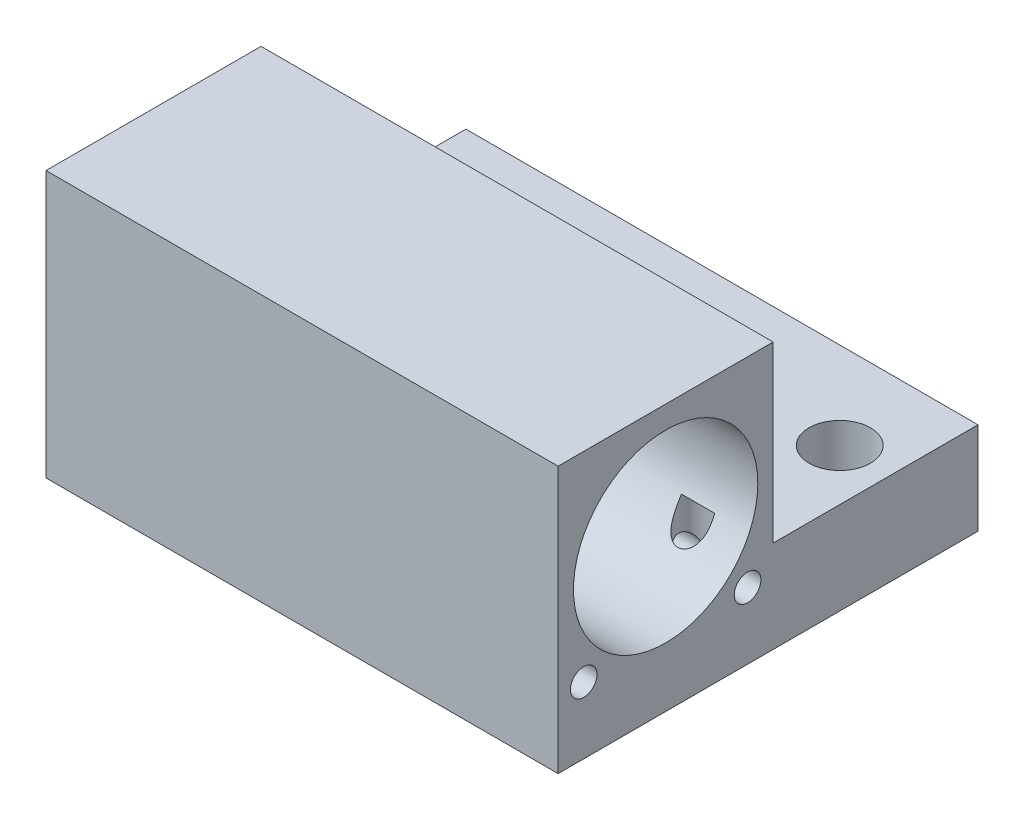
from build123d import *

# Parameters (mm, degrees)
ESQUISSE1_W             = 50
ESQUISSE1_H             = 41
ESQUISSE1_R             = 1.65
ESQUISSE1_R_2           = 3
BOSS_EXTRU_1_DEPTH      = 26
ESQUISSE2_W             = 20
ESQUISSE2_H             = 17
ENL_V_MAT_EXTRU_1_DEPTH = 51
ESQUISSE3_R             = 9
ENL_V_MAT_EXTRU_2_DEPTH = 19.5
ESQUISSE3_3_R           = 1.3
ENL_V_MAT_EXTRU_3_DEPTH = 15
ESQUISSE1_3_R           = 1.65
ENL_V_MAT_EXTRU_4_DEPTH = 11
ESQUISSE4_R             = 7
ENL_V_MAT_EXTRU_5_DEPTH = 51.0000001
ESQUISSE4_3_R           = 9
ENL_V_MAT_EXTRU_6_DEPTH = 13
ESQUISSE4_4_R           = 7.5
ENL_V_MAT_EXTRU_7_DEPTH = 23


with BuildPart() as part:
    # Esquisse1 → Boss.-Extru.1 (new body)
    with BuildSketch(Plane(origin=(0, 0, 0), x_dir=(1, 0, 0), z_dir=(0, 1, 0))):
        with Locations((-25, 20.5)):
            Rectangle(ESQUISSE1_W, ESQUISSE1_H)
        with Locations((-45, 18.35)):
            Circle(ESQUISSE1_R, mode=Mode.SUBTRACT)
        with Locations((-5, 18.35)):
            Circle(ESQUISSE1_R, mode=Mode.SUBTRACT)
        with Locations(Location((-5, 32.5, 0), (0, 0, 270))):  # turned: the seam where the file's is
            Circle(ESQUISSE1_R_2, mode=Mode.SUBTRACT)
        with Locations(Location((-45, 32.5, 0), (0, 0, 270))):  # turned: the seam where the file's is
            Circle(ESQUISSE1_R_2, mode=Mode.SUBTRACT)
        with Locations((-45, 18.35)):
            Circle(ESQUISSE1_R)
        with Locations((-5, 18.35)):
            Circle(ESQUISSE1_R)
    extrude(amount=BOSS_EXTRU_1_DEPTH)

    # Esquisse2 → Enl_v. mat.-Extru.1 (cut, through all)
    with BuildSketch(Plane(origin=(0, 0, 0), x_dir=(0, 0, -1), z_dir=(1, 0, 0))):
        with Locations((31, 17.5)):
            Rectangle(ESQUISSE2_W, ESQUISSE2_H)
    extrude(amount=-ENL_V_MAT_EXTRU_1_DEPTH, mode=Mode.SUBTRACT)

    # Esquisse3 → Enl_v. mat.-Extru.2 (cut)
    with BuildSketch(Plane(origin=(0, 0, 0), x_dir=(0, 0, -1), z_dir=(1, 0, 0))):
        with Locations((10.5, 14.8)):
            Circle(ESQUISSE3_R)
    extrude(amount=-ENL_V_MAT_EXTRU_2_DEPTH, mode=Mode.SUBTRACT)

    # Esquisse3_3 → Enl_v. mat.-Extru.3 (cut)
    with BuildSketch(Plane(origin=(0, 0, 0), x_dir=(0, 0, -1), z_dir=(1, 0, 0))):
        with Locations((2.5, 6.5)):
            Circle(ESQUISSE3_3_R)
        with Locations((18.5, 6.5)):
            Circle(ESQUISSE3_3_R)
    extrude(amount=-ENL_V_MAT_EXTRU_3_DEPTH, mode=Mode.SUBTRACT)

    # Esquisse1_3 → Enl_v. mat.-Extru.4 (cut)
    with BuildSketch(Plane(origin=(0, 0, 0), x_dir=(1, 0, 0), z_dir=(0, 1, 0))):
        with Locations(Location((-5, 18.35, 0), (0, 0, 169.22643943))):  # turned: the seam where the file's is
            Circle(ESQUISSE1_3_R)
        with Locations(Location((-45, 18.35, 0), (0, 0, 270))):  # turned: the seam where the file's is
            Circle(ESQUISSE1_3_R)
    extrude(amount=ENL_V_MAT_EXTRU_4_DEPTH, mode=Mode.SUBTRACT)

    # Esquisse4 → Enl_v. mat.-Extru.5 (cut, through all)
    with BuildSketch(Plane.ZY.offset(50)):
        with Locations((-10.5, 14.8)):
            Circle(ESQUISSE4_R)
    extrude(amount=-ENL_V_MAT_EXTRU_5_DEPTH, mode=Mode.SUBTRACT)

    # Esquisse4_3 → Enl_v. mat.-Extru.6 (cut)
    with BuildSketch(Plane.ZY.offset(50)):
        with Locations(Location((-10.5, 14.8, 0), (0, 0, 180))):  # turned: the seam where the file's is
            Circle(ESQUISSE4_3_R)
    extrude(amount=-ENL_V_MAT_EXTRU_6_DEPTH, mode=Mode.SUBTRACT)

    # Esquisse4_4 → Enl_v. mat.-Extru.7 (cut)
    with BuildSketch(Plane.ZY.offset(50)):
        with Locations((-10.5, 14.8)):
            Circle(ESQUISSE4_4_R)
    extrude(amount=-ENL_V_MAT_EXTRU_7_DEPTH, mode=Mode.SUBTRACT)


solid = part.part
